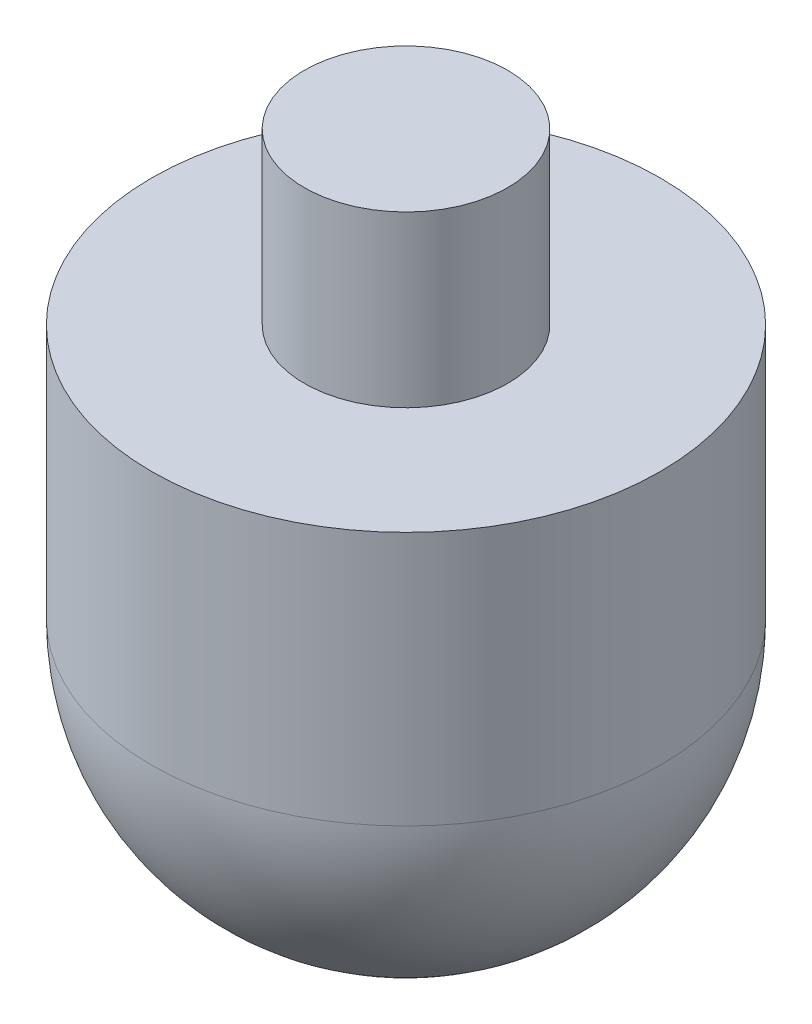
from build123d import *


with BuildPart() as part:
    # Sketch1 → Revolve1 (revolve)
    with BuildSketch(Plane.XY, mode=Mode.PRIVATE) as revolve1_sk:
        with BuildLine():
            Line((15, 0), (15, 15))
            Line((15, 15), (6, 15))
            Line((6, 15), (6, 25))
            Line((6, 25), (0, 25))
            Line((0, 25), (0, -15))
            ThreePointArc((0, -15), (10.606601718, -10.606601718), (15, 0))
        make_face()
    revolve(revolve1_sk.sketch.rotate(Axis((0, 0, 0), (0, 1, 0)), 90), axis=Axis((0, 0, 0), (0, 1, 0)))  # turned: the seam where the file's is


solid = part.part
